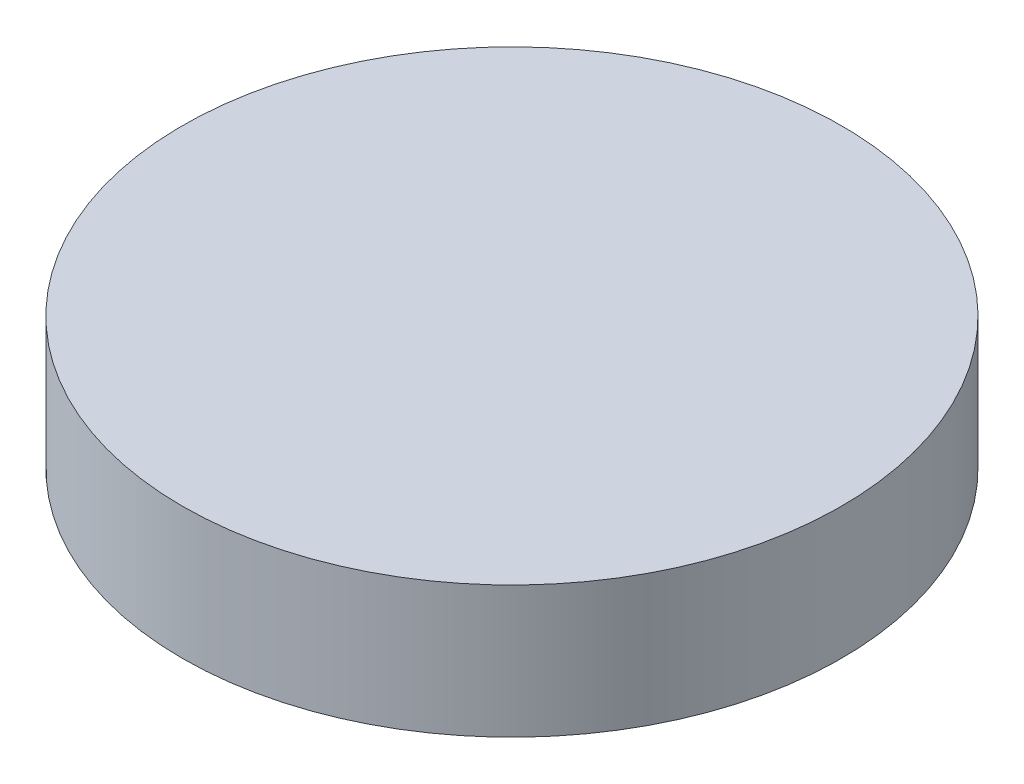
from build123d import *

# Parameters (mm, degrees)
SKETCH1_R      = 6.35
EXTRUDE1_DEPTH = 2.54


with BuildPart() as part:
    # Sketch1 → Extrude1 (new body)
    with BuildSketch(Plane(origin=(0, 0, 0), x_dir=(1, 0, 0), z_dir=(0, 1, 0))):
        Circle(SKETCH1_R)
    extrude(amount=EXTRUDE1_DEPTH)


solid = part.part
